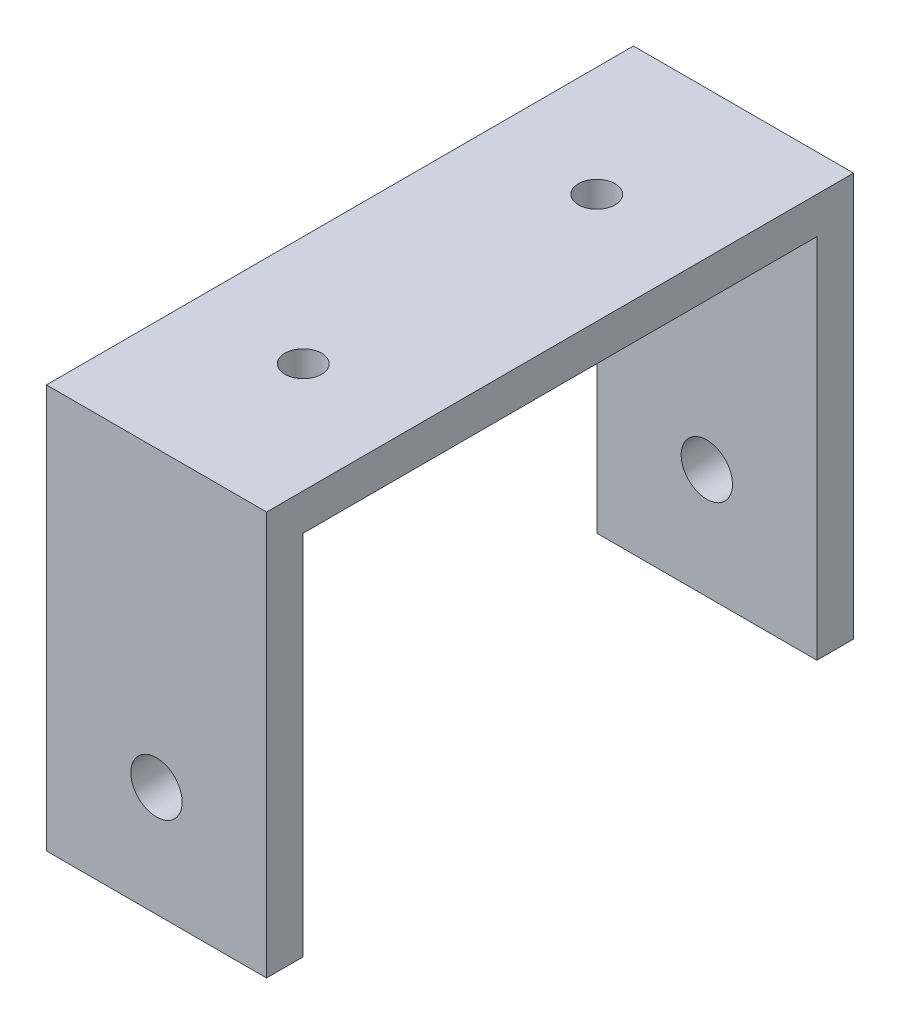
from build123d import *

# Parameters (mm, degrees)
SKETCH1_W           = 30
SKETCH1_H           = 55
BOSS_EXTRUDE1_DEPTH = 80
SKETCH2_W           = 70
SKETCH2_H           = 50
CUT_EXTRUDE1_DEPTH  = 60
SKETCH3_R           = 3.5
CUT_EXTRUDE2_DEPTH  = 117
SKETCH4_R           = 2.5
CUT_EXTRUDE3_DEPTH  = 42


with BuildPart() as part:
    # Sketch1 → Boss-Extrude1 (new body)
    with BuildSketch(Plane.XY):
        Rectangle(SKETCH1_W, SKETCH1_H)
    extrude(amount=BOSS_EXTRUDE1_DEPTH)

    # Sketch2 → Cut-Extrude1 (cut)
    with BuildSketch(Plane(origin=(15, 0, 0), x_dir=(0, 0, -1), z_dir=(1, 0, 0))):
        with Locations((-40, -2.5)):
            Rectangle(SKETCH2_W, SKETCH2_H)
    extrude(amount=-CUT_EXTRUDE1_DEPTH, mode=Mode.SUBTRACT)

    # Sketch3 → Cut-Extrude2 (cut)
    with BuildSketch(Plane.XY.offset(80)):
        with Locations((0, -12.5)):
            Circle(SKETCH3_R)
    extrude(amount=-CUT_EXTRUDE2_DEPTH, mode=Mode.SUBTRACT)

    # Sketch4 → Cut-Extrude3 (cut)
    with BuildSketch(Plane(origin=(0, 0, 0), x_dir=(1, 0, 0), z_dir=(0, 1, 0))):
        with Locations((0, -20)):
            Circle(SKETCH4_R)
        with Locations((0, -60)):
            Circle(SKETCH4_R)
    extrude(amount=CUT_EXTRUDE3_DEPTH, mode=Mode.SUBTRACT)


solid = part.part
